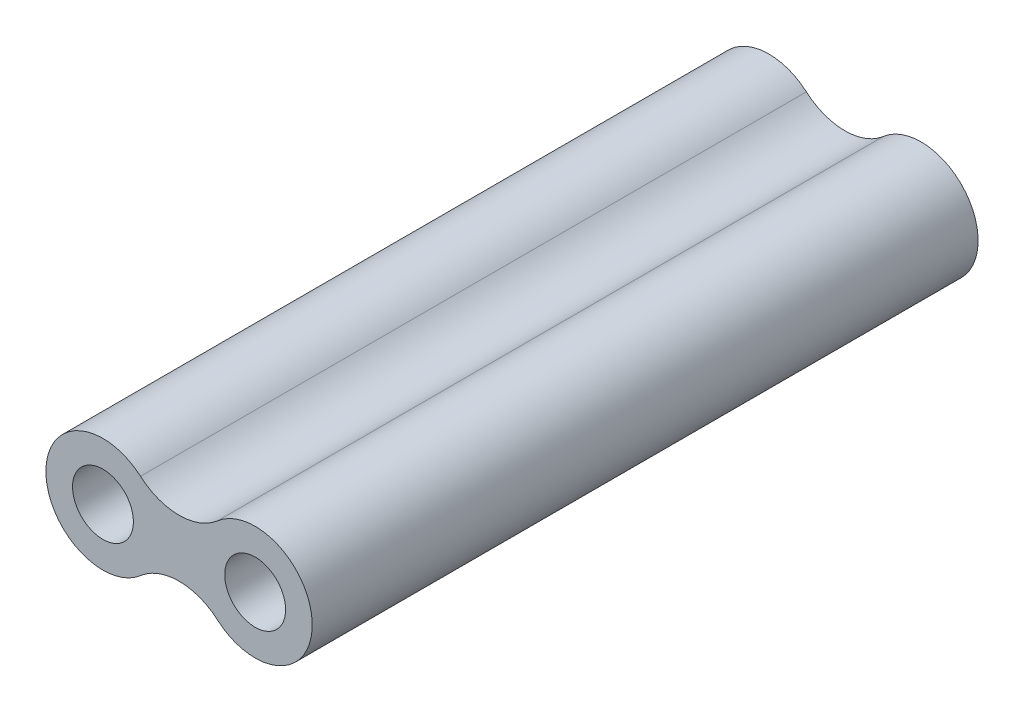
from build123d import *

# Parameters (mm, degrees)
SKETCH1_R                       = 3
BOSS_EXTRUDE1_DEPTH             = 17.5
M3_CLEARANCE_HOLE_D             = 3.2
BOSS_EXTRUDE2_REACH             = 20.007
BOSS_EXTRUDE2_DIRECTION_2_REACH = 20.007
M3_CLEARANCE_HOLE2_D            = 3.2


with BuildPart() as part:
    # Sketch1 → Boss-Extrude1 (new, symmetric)
    with BuildSketch(Plane.XY):
        Circle(SKETCH1_R)
    extrude(amount=BOSS_EXTRUDE1_DEPTH, both=True)

    # M3 Clearance Hole (through all)
    with Locations(Plane.XY.offset(17.5)):
        with Locations((0, 0)):
            Hole(M3_CLEARANCE_HOLE_D / 2)

    # Boss-Extrude2: up to this face of the body (flat: up to its plane)
    boss_extrude2_end = Plane(part.part.faces().sort_by_distance((-2.915147186, 0, 17.5))[0])
    # Sketch2 → Boss-Extrude2 (add, up to the picked face)
    with BuildSketch(Plane.XY, mode=Mode.PRIVATE) as boss_extrude2_sk1:
        with BuildLine():
            ThreePointArc((6.02739726, -2.260273973), (11, 0), (6.02739726, 2.260273973))
            ThreePointArc((6.02739726, 2.260273973), (4, 1.5), (1.97260274, 2.260273973))
            ThreePointArc((1.97260274, 2.260273973), (3, 0), (1.97260274, -2.260273973))
            ThreePointArc((1.97260274, -2.260273973), (4, -1.5), (6.02739726, -2.260273973))
        make_face()
    boss_extrude2_tool1 = split(extrude(boss_extrude2_sk1.sketch, amount=BOSS_EXTRUDE2_REACH, mode=Mode.PRIVATE), bisect_by=boss_extrude2_end, keep=Keep.BOTH, mode=Mode.PRIVATE)
    add(boss_extrude2_tool1.solids().sort_by(Axis((7.146911, 0, 0), (0, 0, 1)))[0])

    # Boss-Extrude2 direction 2: up to this face of the body (flat: up to its plane)
    boss_extrude2_direction_2_end = Plane(part.part.faces().sort_by_distance((-2.915147186, 0, -17.5))[0])
    # Sketch2 → Boss-Extrude2 direction 2 (add, up to the picked face)
    with BuildSketch(Plane.XY, mode=Mode.PRIVATE) as boss_extrude2_direction_2_sk1:
        with BuildLine():
            ThreePointArc((6.02739726, -2.260273973), (11, 0), (6.02739726, 2.260273973))
            ThreePointArc((6.02739726, 2.260273973), (4, 1.5), (1.97260274, 2.260273973))
            ThreePointArc((1.97260274, 2.260273973), (3, 0), (1.97260274, -2.260273973))
            ThreePointArc((1.97260274, -2.260273973), (4, -1.5), (6.02739726, -2.260273973))
        make_face()
    boss_extrude2_direction_2_tool1 = split(extrude(boss_extrude2_direction_2_sk1.sketch, amount=-BOSS_EXTRUDE2_DIRECTION_2_REACH, mode=Mode.PRIVATE), bisect_by=boss_extrude2_direction_2_end, keep=Keep.BOTH, mode=Mode.PRIVATE)
    add(boss_extrude2_direction_2_tool1.solids().sort_by(Axis((7.146911, 0, 0), (0, 0, -1)))[0])

    # M3 Clearance Hole2 (through all)
    with Locations(Plane.XY.offset(17.5)):
        with Locations((8, 0)):
            Hole(M3_CLEARANCE_HOLE2_D / 2)


solid = part.part
